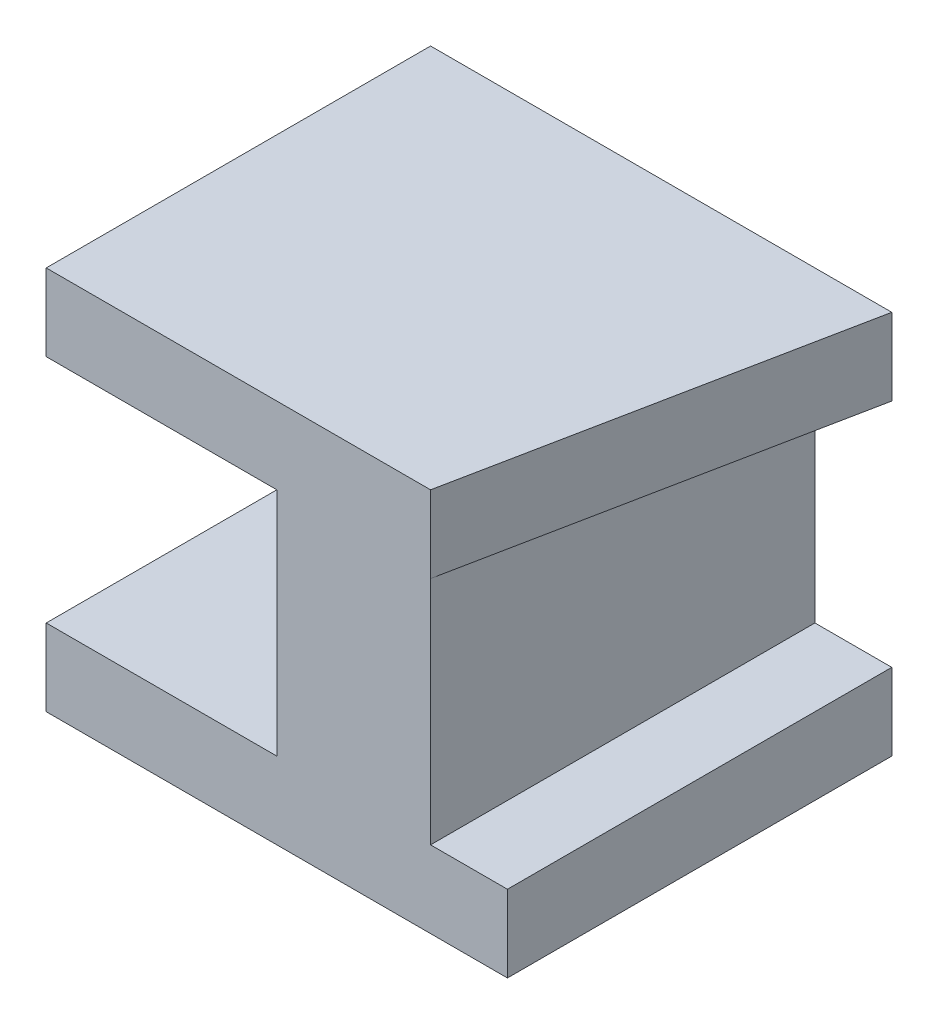
from build123d import *

# Parameters (mm, degrees)
BOSS_EXTRUDE1_DEPTH = 25
SKETCH2_W           = 10
SKETCH2_H           = 15
BOSS_EXTRUDE2_DEPTH = 10
SKETCH3_W           = 25
SKETCH3_H           = 5
BOSS_EXTRUDE3_DEPTH = 5
CUT_EXTRUDE1_DEPTH  = 5


with BuildPart() as part:
    # Sketch1 → Boss-Extrude1 (new body)
    with BuildSketch(Plane.XY):
        Polygon((0, 0), (25, 0), (25, 25), (0, 25), (0, 20), (15, 20), (15, 5), (0, 5), align=None)
    extrude(amount=BOSS_EXTRUDE1_DEPTH)

    # Sketch2 → Boss-Extrude2 (add)
    with BuildSketch(Plane.ZY.offset(-15)):
        with Locations((5, 12.5)):
            Rectangle(SKETCH2_W, SKETCH2_H)
    extrude(amount=BOSS_EXTRUDE2_DEPTH)

    # Sketch3 → Boss-Extrude3 (add)
    with BuildSketch(Plane(origin=(25, 0, 0), x_dir=(0, 0, -1), z_dir=(1, 0, 0))):
        with Locations((-12.5, 22.5)):
            Rectangle(SKETCH3_W, SKETCH3_H)
        with Locations((-12.5, 2.5)):
            Rectangle(SKETCH3_W, SKETCH3_H)
    extrude(amount=BOSS_EXTRUDE3_DEPTH)

    # Sketch4 → Cut-Extrude1 (cut)
    with BuildSketch(Plane(origin=(0, 25, 0), x_dir=(1, 0, 0), z_dir=(0, 1, 0))):
        Polygon((25, -25), (30, 0), (30, -25), align=None)
    extrude(amount=-CUT_EXTRUDE1_DEPTH, mode=Mode.SUBTRACT)


solid = part.part
